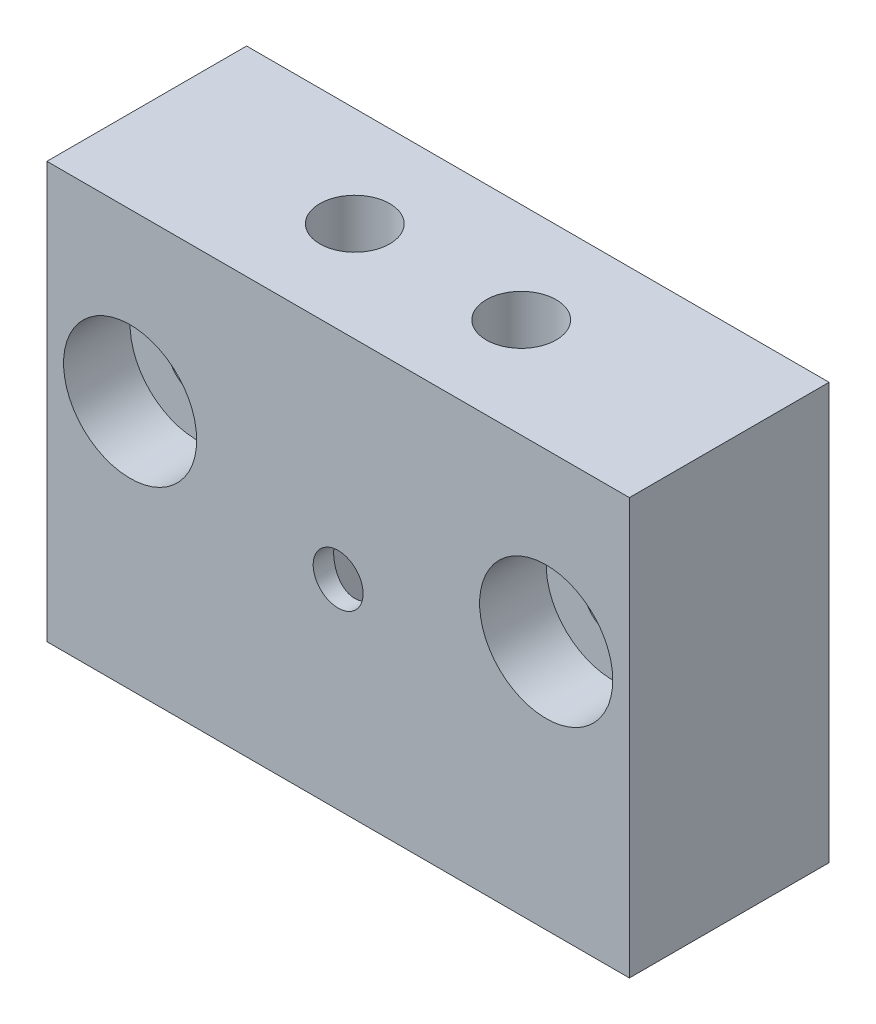
from build123d import *

# Parameters (mm, degrees)
SKETCH1_W           = 35
SKETCH1_H           = 12
BOSS_EXTRUDE1_DEPTH = 25
SKETCH2_R           = 5
CUT_EXTRUDE1_DEPTH  = 18
SKETCH3_R           = 2.1
CUT_EXTRUDE2_DEPTH  = 15
SKETCH4_R           = 1.5
CUT_EXTRUDE3_DEPTH  = 7
SKETCH5_R           = 1.75
CUT_EXTRUDE4_DEPTH  = 13
SKETCH6_R           = 4
CUT_EXTRUDE5_DEPTH  = 4


with BuildPart() as part:
    # Sketch1 → Boss-Extrude1 (new body)
    with BuildSketch(Plane(origin=(0, 0, 0), x_dir=(1, 0, 0), z_dir=(0, 1, 0))):
        Rectangle(SKETCH1_W, SKETCH1_H)
    extrude(amount=BOSS_EXTRUDE1_DEPTH)

    # Sketch2 → Cut-Extrude1 (cut)
    with BuildSketch(Plane.XZ):
        Circle(SKETCH2_R)
    extrude(amount=-CUT_EXTRUDE1_DEPTH, mode=Mode.SUBTRACT)

    # Sketch3 → Cut-Extrude2 (cut)
    with BuildSketch(Plane(origin=(0, 25, 0), x_dir=(1, 0, 0), z_dir=(0, 1, 0))):
        with Locations((-5, 0)):
            Circle(SKETCH3_R)
        with Locations((5, 0)):
            Circle(SKETCH3_R)
    extrude(amount=-CUT_EXTRUDE2_DEPTH, mode=Mode.SUBTRACT)

    # Sketch4 → Cut-Extrude3 (cut)
    with BuildSketch(Plane.XY.offset(6)):
        with Locations((0, 12)):
            Circle(SKETCH4_R)
    extrude(amount=-CUT_EXTRUDE3_DEPTH, mode=Mode.SUBTRACT)

    # Sketch5 → Cut-Extrude4 (cut, through all)
    with BuildSketch(Plane.XY.offset(6)):
        with Locations((-12.5, 15)):
            Circle(SKETCH5_R)
        with Locations((12.5, 15)):
            Circle(SKETCH5_R)
    extrude(amount=-CUT_EXTRUDE4_DEPTH, mode=Mode.SUBTRACT)

    # Sketch6 → Cut-Extrude5 (cut)
    with BuildSketch(Plane.XY.offset(6)):
        with Locations((-12.5, 15)):
            Circle(SKETCH6_R)
        with Locations((12.5, 15)):
            Circle(SKETCH6_R)
    extrude(amount=-CUT_EXTRUDE5_DEPTH, mode=Mode.SUBTRACT)


solid = part.part
